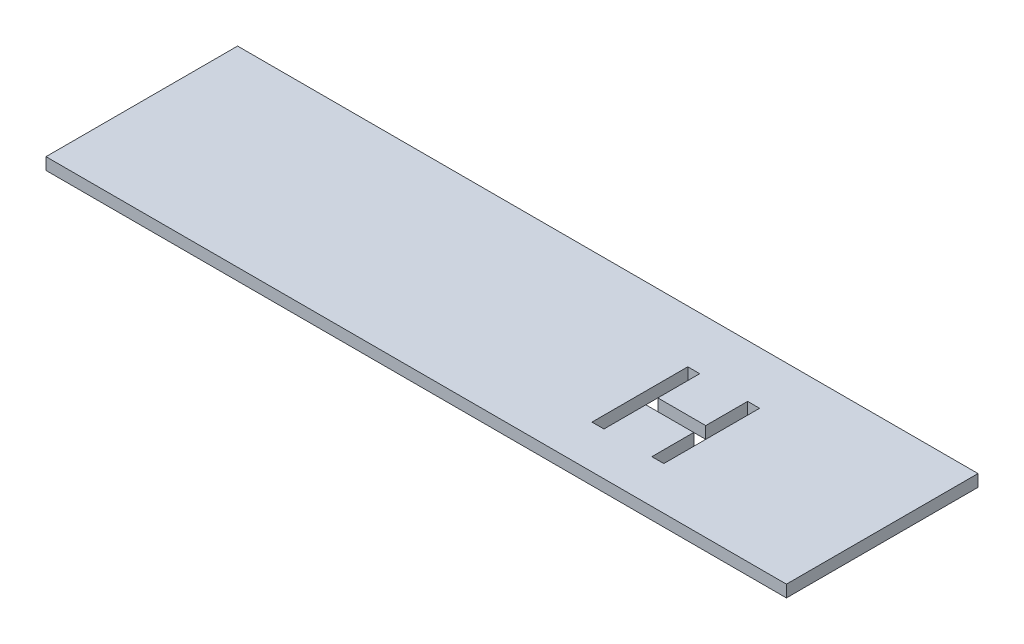
from build123d import *

# Parameters (mm, degrees)
SKETCH1_W           = 196.342
SKETCH1_H           = 50.8
BOSS_EXTRUDE1_DEPTH = 3.175
CUT_EXTRUDE1_DEPTH  = 7.62


with BuildPart() as part:
    # Sketch1 → Boss-Extrude1 (new body)
    with BuildSketch(Plane(origin=(0, 0, 0), x_dir=(1, 0, 0), z_dir=(0, 1, 0))):
        with Locations((98.171, 25.4)):
            Rectangle(SKETCH1_W, SKETCH1_H)
    extrude(amount=BOSS_EXTRUDE1_DEPTH)

    # Sketch2 → Cut-Extrude1 (cut)
    with BuildSketch(Plane.XZ):
        Polygon((136.525, -25.7175), (136.525, -36.83), (133.35, -36.83), (133.35, -11.43), (136.525, -11.43), (136.525, -22.5425), (149.225, -22.5425), (149.225, -11.43), (152.4, -11.43), (152.4, -36.83), (149.225, -36.83), (149.225, -25.7175), align=None)
    extrude(amount=-CUT_EXTRUDE1_DEPTH, mode=Mode.SUBTRACT)


solid = part.part
